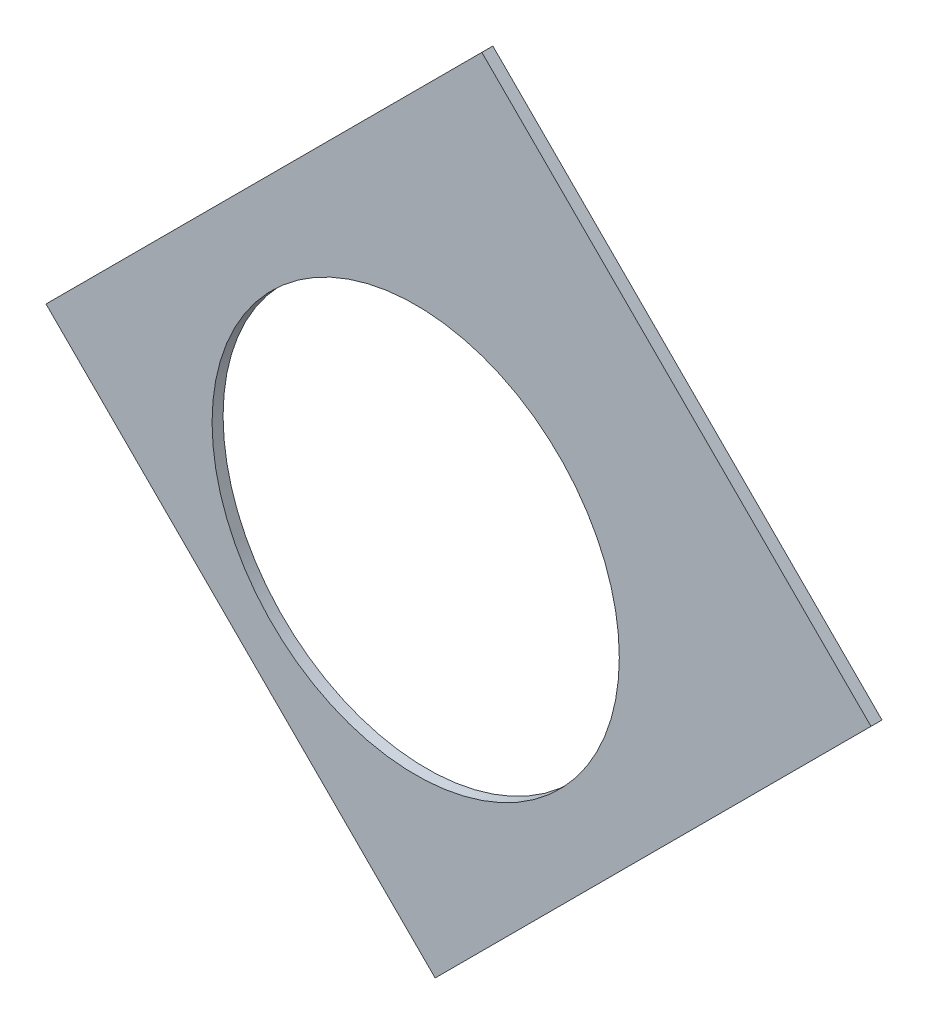
from build123d import *

# Parameters (mm, degrees)
BOSS_EXTRUDE1_DEPTH = 0.254
SKETCH2_R           = 4.699
CUT_EXTRUDE1_DEPTH  = 1.254
SKETCH3_W           = 2.54
SKETCH3_H           = 0.635
CUT_EXTRUDE2_DEPTH  = 1.254
SKETCH5_OUTSIDE_W   = 121.447
SKETCH5_OUTSIDE_H   = 109.618
CUT_EXTRUDE5_DEPTH  = 1.254


with BuildPart() as part:
    # Sketch1 → Boss-Extrude1 (new body)
    with BuildSketch(Plane.XY):
        with BuildLine():
            Line((67.21146711, 76.191723231), (8.696654013, 17.676910134))
            Line((8.696654013, 17.676910134), (7.228954972, 14.133571205))
            ThreePointArc((7.228954972, 14.133571205), (14.666587579, 6.075099489), (15.105587123, -4.88230096))
            Line((15.105587123, -4.88230096), (18.648926052, -6.35))
            Line((18.648926052, -6.35), (101.401368334, -6.35))
            ThreePointArc((101.401368334, -6.35), (93.866160503, 38.880636728), (67.21146711, 76.191723231))
        make_face()
        with BuildLine():
            Line((88.672924278, 6.35), (27.86051193, 6.35))
            ThreePointArc((27.86051193, 6.35), (26.399857642, 10.93517908), (24.190484974, 15.210228852))
            Line((24.190484974, 15.210228852), (67.191354125, 58.211098004))
            ThreePointArc((67.191354125, 58.211098004), (82.13289044, 34.020557137), (88.672924278, 6.35))
        make_face(mode=Mode.SUBTRACT)
    extrude(amount=BOSS_EXTRUDE1_DEPTH)

    # Sketch2 → Cut-Extrude1 (cut, through all)
    with BuildSketch(Plane.XY.offset(0.254)):
        with Locations((22.225, 0)):
            Circle(SKETCH2_R)
        with Locations((36.195, 0)):
            Circle(SKETCH2_R)
        with Locations((61.722, 0)):
            Circle(SKETCH2_R)
        with Locations((75.692, 0)):
            Circle(SKETCH2_R)
        with Locations((95.25, 0)):
            Circle(SKETCH2_R)
        with Locations((15.715448212, 15.715448212)):
            Circle(SKETCH2_R)
        with Locations((25.593729945, 25.593729945)):
            Circle(SKETCH2_R)
        with Locations((43.644044748, 43.644044748)):
            Circle(SKETCH2_R)
        with Locations((53.522326482, 53.522326482)):
            Circle(SKETCH2_R)
        with Locations((92.004434954, 24.652514046)):
            Circle(SKETCH2_R)
        with Locations((82.48891971, 47.625)):
            Circle(SKETCH2_R)
        with Locations((67.351920908, 67.351920908)):
            Circle(SKETCH2_R)
    extrude(amount=-CUT_EXTRUDE1_DEPTH, mode=Mode.SUBTRACT)

    # Sketch3 → Cut-Extrude2 (cut, through all)
    with BuildSketch(Plane.XY.offset(0.254)):
        Polygon((15.266435406, 24.246691527), (17.06248663, 26.042742751), (17.511499436, 25.593729945), (15.715448212, 23.797678721), align=None)
        Polygon((44.991083167, 53.971339288), (43.195031942, 52.175288063), (43.644044748, 51.726275257), (45.440095973, 53.522326482), align=None)
        with Locations((29.21, -6.0325)):
            Rectangle(SKETCH3_W, SKETCH3_H)
        with Locations((68.707, -6.0325)):
            Rectangle(SKETCH3_W, SKETCH3_H)
        Polygon((29.230733674, 38.210989795), (31.026784898, 40.007041019), (31.475797704, 39.558028213), (29.67974648, 37.761976989), align=None)
        Polygon((56.845021246, 65.825277367), (55.048970022, 64.029226143), (55.497982828, 63.580213337), (57.294034052, 65.376264561), align=None)
        with Locations((48.9585, -6.0325)):
            Rectangle(SKETCH3_W, SKETCH3_H)
        with Locations((85.471, -6.0325)):
            Rectangle(SKETCH3_W, SKETCH3_H)
        Polygon((99.935462164, 14.437711971), (100.266998693, 11.919442024), (101.526133667, 12.085210288), (101.194597138, 14.603480236), align=None)
        Polygon((93.765504959, 37.464305742), (94.938831965, 37.950313702), (93.966816047, 40.296967714), (92.793489041, 39.810959755), align=None)
        Polygon((79.327792988, 62.471156422), (80.874047017, 60.456038938), (81.88160576, 61.229165953), (80.33535173, 63.244283437), align=None)
        Polygon((13.593916116, 7.005422516), (14.565932035, 4.658768503), (15.739259041, 5.144776462), (14.767243123, 7.491430475), align=None)
    extrude(amount=-CUT_EXTRUDE2_DEPTH, mode=Mode.SUBTRACT)

    # Sketch5 outside → Cut-Extrude5 (cut, through all)
    with BuildSketch(Plane.XY.offset(0.254)):
        with Locations((54.4145, 34.921)):
            Rectangle(SKETCH5_OUTSIDE_W, SKETCH5_OUTSIDE_H)
        Polygon((53.971339288, 44.991083167), (64.029226143, 55.048970022), (55.048970022, 64.029226143), (44.991083167, 53.971339288), align=None, mode=Mode.SUBTRACT)
    extrude(amount=-CUT_EXTRUDE5_DEPTH, mode=Mode.SUBTRACT)


solid = part.part
